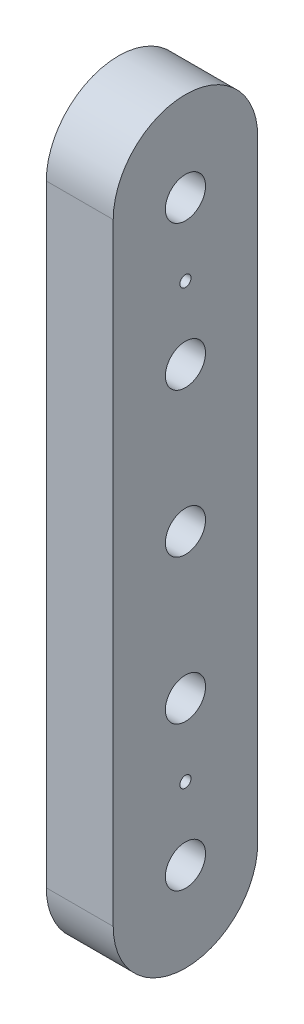
from build123d import *

# Parameters (mm, degrees)
BOSS_EXTRUDE1_DEPTH = 76.2
CUT_EXTRUDE1_REACH  = 78.2
SKETCH3_R           = 22.86
CUT_EXTRUDE2_REACH  = 78.2
SKETCH4_R           = 6.35


with BuildPart() as part:
    # Sketch2 → Boss-Extrude1 (new body)
    with BuildSketch(Plane.ZY.offset(-1066.346797213)):
        with BuildLine():
            Line((-82.55, 1331.163756946), (-82.55, 2028.051006195))
            ThreePointArc((-82.55, 2028.051006195), (-164.799803954, 2110.300810149), (-247.049607907, 2028.051006195))
            Line((-247.049607907, 2028.051006195), (-247.049607907, 1331.163756946))
            ThreePointArc((-247.049607907, 1331.163756946), (-164.799803954, 1248.913952992), (-82.55, 1331.163756946))
        make_face()
    extrude(amount=BOSS_EXTRUDE1_DEPTH)

    # Sketch3 → Cut-Extrude1 (cut, up to next)
    with BuildSketch(Plane(origin=(1066.346797213, 0, 0), x_dir=(0, 0, -1), z_dir=(1, 0, 0)), mode=Mode.PRIVATE) as cut_extrude1_sk1:
        with Locations((164.799803954, 1844.15409586)):
            Circle(SKETCH3_R)
    cut_extrude1_tool1 = extrude(cut_extrude1_sk1.sketch, amount=-CUT_EXTRUDE1_REACH, mode=Mode.PRIVATE) & part.part
    add(cut_extrude1_tool1.solids().sort_by_distance((1066.346797, 1844.154096, -164.799804))[0], mode=Mode.SUBTRACT)
    # Sketch3 → Cut-Extrude1 (cut, up to next)
    with BuildSketch(Plane(origin=(1066.346797213, 0, 0), x_dir=(0, 0, -1), z_dir=(1, 0, 0)), mode=Mode.PRIVATE) as cut_extrude1_sk2:
        with Locations((164.799803954, 1679.607381571)):
            Circle(SKETCH3_R)
    cut_extrude1_tool2 = extrude(cut_extrude1_sk2.sketch, amount=-CUT_EXTRUDE1_REACH, mode=Mode.PRIVATE) & part.part
    add(cut_extrude1_tool2.solids().sort_by_distance((1066.346797, 1679.607382, -164.799804))[0], mode=Mode.SUBTRACT)
    # Sketch3 → Cut-Extrude1 (cut, up to next)
    with BuildSketch(Plane(origin=(1066.346797213, 0, 0), x_dir=(0, 0, -1), z_dir=(1, 0, 0)), mode=Mode.PRIVATE) as cut_extrude1_sk3:
        with Locations((164.799803954, 2008.700810149)):
            Circle(SKETCH3_R)
    cut_extrude1_tool3 = extrude(cut_extrude1_sk3.sketch, amount=-CUT_EXTRUDE1_REACH, mode=Mode.PRIVATE) & part.part
    add(cut_extrude1_tool3.solids().sort_by_distance((1066.346797, 2008.70081, -164.799804))[0], mode=Mode.SUBTRACT)
    # Sketch3 → Cut-Extrude1 (cut, up to next)
    with BuildSketch(Plane(origin=(1066.346797213, 0, 0), x_dir=(0, 0, -1), z_dir=(1, 0, 0)), mode=Mode.PRIVATE) as cut_extrude1_sk4:
        with Locations((164.799803954, 1515.060667281)):
            Circle(SKETCH3_R)
    cut_extrude1_tool4 = extrude(cut_extrude1_sk4.sketch, amount=-CUT_EXTRUDE1_REACH, mode=Mode.PRIVATE) & part.part
    add(cut_extrude1_tool4.solids().sort_by_distance((1066.346797, 1515.060667, -164.799804))[0], mode=Mode.SUBTRACT)
    # Sketch3 → Cut-Extrude1 (cut, up to next)
    with BuildSketch(Plane(origin=(1066.346797213, 0, 0), x_dir=(0, 0, -1), z_dir=(1, 0, 0)), mode=Mode.PRIVATE) as cut_extrude1_sk5:
        with Locations((164.799803954, 1350.513952992)):
            Circle(SKETCH3_R)
    cut_extrude1_tool5 = extrude(cut_extrude1_sk5.sketch, amount=-CUT_EXTRUDE1_REACH, mode=Mode.PRIVATE) & part.part
    add(cut_extrude1_tool5.solids().sort_by_distance((1066.346797, 1350.513953, -164.799804))[0], mode=Mode.SUBTRACT)

    # Sketch4 → Cut-Extrude2 (cut, up to next)
    with BuildSketch(Plane(origin=(1066.346797213, 0, 0), x_dir=(0, 0, -1), z_dir=(1, 0, 0)), mode=Mode.PRIVATE) as cut_extrude2_sk1:
        with Locations((164.799803954, 1926.427453004)):
            Circle(SKETCH4_R)
    cut_extrude2_tool1 = extrude(cut_extrude2_sk1.sketch, amount=-CUT_EXTRUDE2_REACH, mode=Mode.PRIVATE) & part.part
    add(cut_extrude2_tool1.solids().sort_by_distance((1066.346797, 1926.427453, -164.799804))[0], mode=Mode.SUBTRACT)
    # Sketch4 → Cut-Extrude2 (cut, up to next)
    with BuildSketch(Plane(origin=(1066.346797213, 0, 0), x_dir=(0, 0, -1), z_dir=(1, 0, 0)), mode=Mode.PRIVATE) as cut_extrude2_sk2:
        with Locations((164.799803954, 1432.787310137)):
            Circle(SKETCH4_R)
    cut_extrude2_tool2 = extrude(cut_extrude2_sk2.sketch, amount=-CUT_EXTRUDE2_REACH, mode=Mode.PRIVATE) & part.part
    add(cut_extrude2_tool2.solids().sort_by_distance((1066.346797, 1432.78731, -164.799804))[0], mode=Mode.SUBTRACT)


solid = part.part
